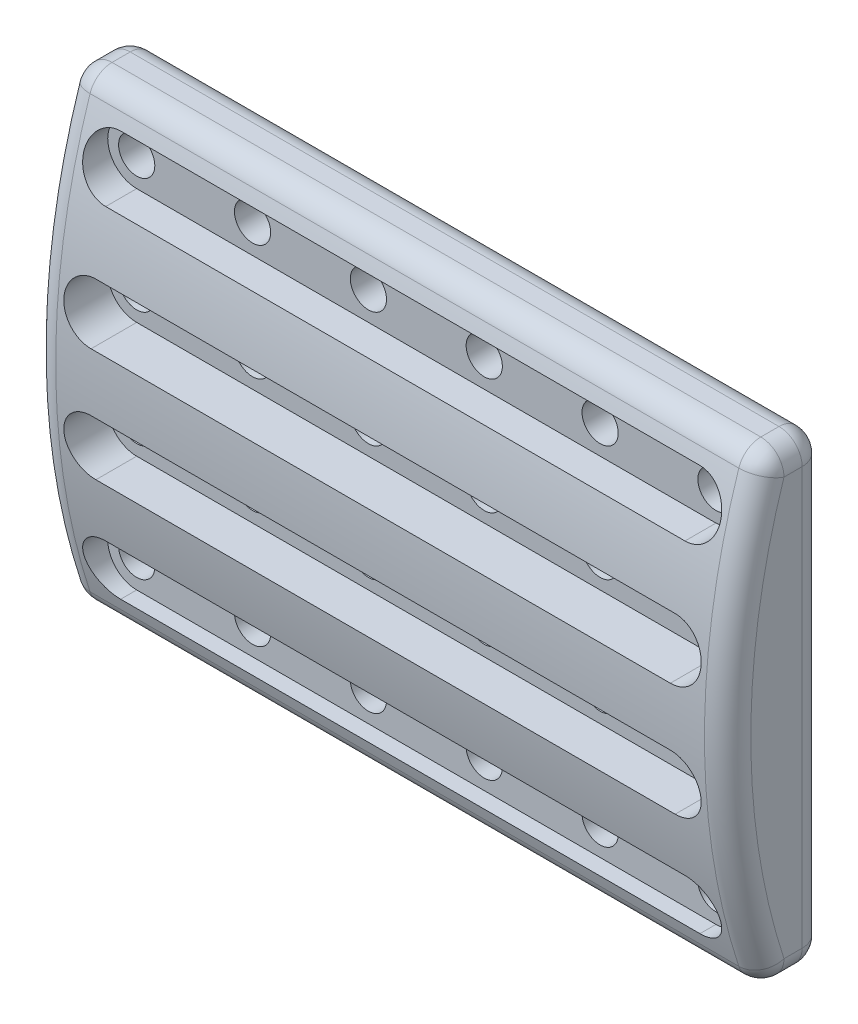
from build123d import *

# Parameters (mm, degrees)
BOSS_EXTRUDE1_DEPTH             = 76.2
FILLET1_R                       = 2.54
CUT_EXTRUDE1_DEPTH              = 5.08
F_5_32_0_15625_DIAMETER_HOLE1_D = 3.96875


with BuildPart() as part:
    # Sketch3 → Boss-Extrude1 (new body)
    with BuildSketch(Plane(origin=(0, 0, 0), x_dir=(0, 0, -1), z_dir=(1, 0, 0))):
        with BuildLine():
            ThreePointArc((-0.5955037838105575, 1.7517241379310349), (-0.3542263859949928, 1.225338953378048), (-1.2301e-13, 0.7672780265587602))
            Line((0, 0.7672780265588011), (0, 50.0327219734412))
            ThreePointArc((-1.2323e-13, 50.03272197344124), (-0.3542263859949948, 49.57466104662194), (-0.5955037838105568, 49.04827586206895))
            ThreePointArc((-0.5955037838105568, 49.04827586206895), (-4.35795103144676, 25.399999999999988), (-0.5955037838105568, 1.7517241379310349))
        make_face()
        with BuildLine():
            Line((0, 50.0327219734412), (0, 0.7672780265588011))
            ThreePointArc((-1.2301e-13, 0.7672780265587602), (0.8319424657603935, 0.19966735136426017), (1.8190813079349, -4.4e-16))
            Line((1.8190813079349, 0), (3.8099999999999925, 0))
            ThreePointArc((3.8099999999999925, 4.4e-16), (5.606051224213842, 0.7439487757861691), (6.350000000000011, 2.5400000000000182))
            Line((6.350000000000011, 2.5400000000000205), (6.3500000000000005, 48.26))
            ThreePointArc((6.350000000000003, 48.26), (5.606051224213832, 50.05605122421383), (3.81, 50.8))
            Line((3.8100000000000005, 50.8), (1.8190813079348995, 50.8))
            ThreePointArc((1.8190813079348995, 50.8), (0.8319424657603925, 50.60033264863574), (-1.2323e-13, 50.03272197344124))
        make_face()
    extrude(amount=BOSS_EXTRUDE1_DEPTH)

    # Fillet1
    fillet1_edges = [part.edges().sort_by_distance(p)[0] for p in [
        (0, 50.315945122036965, -0.3275419503675465),
        (0, 50.8, -2.81454065396745),
        (76.2, 0, -2.8145406539674465),
        (0, 50.05605122421383, -5.606051224213833),
        (0, 25.40000000000001, -6.350000000000006),
        (0, 0.7439487757861691, -5.606051224213842),
        (0, 0, -2.8145406539674465),
        (0, 0.4840548779630356, -0.32754195036755385),
        (76.2, 0.7439487757861691, -5.606051224213842),
        (76.2, 25.40000000000001, -6.350000000000006),
        (76.2, 50.05605122421383, -5.606051224213833),
        (76.2, 50.8, -2.81454065396745),
        (76.2, 50.31594512203697, -0.3275419503675483),
        (76.2, 25.399999999999988, 4.35795103144676),
        (76.2, 0.48405487796303426, -0.32754195036755385),
        (0, 25.399999999999988, 4.35795103144676),
    ]]
    fillet(fillet1_edges, radius=FILLET1_R)

    # Sketch5 → Cut-Extrude1 (cut)
    with BuildSketch(Plane(origin=(0, -9.9e-16, 4.368799999999987), x_dir=(-1, 0, 0), z_dir=(0, 2.3e-16, -1))):
        with BuildLine():
            Line((-6.3500000000000085, 47.625), (-69.85000000000002, 47.62499999999999))
            ThreePointArc((-69.85000000000002, 47.62499999999999), (-73.02500000000002, 44.449999999999996), (-69.85000000000002, 41.275))
            Line((-69.85000000000002, 41.275), (-6.3500000000000085, 41.275))
            ThreePointArc((-6.3500000000000085, 41.275), (-3.1750000000000114, 44.449999999999996), (-6.3500000000000085, 47.625))
        make_face()
        with BuildLine():
            Line((-6.34999999999987, 34.925), (-69.84999999999988, 34.925))
            ThreePointArc((-69.84999999999988, 34.925), (-73.02499999999988, 31.75), (-69.84999999999988, 28.575000000000003))
            Line((-69.84999999999988, 28.575000000000003), (-6.34999999999987, 28.575000000000003))
            ThreePointArc((-6.34999999999987, 28.575000000000003), (-3.174999999999873, 31.75), (-6.34999999999987, 34.925))
        make_face()
        with BuildLine():
            Line((-6.34999999999987, 15.875000000000014), (-69.84999999999988, 15.875000000000014))
            ThreePointArc((-69.84999999999988, 15.875000000000014), (-73.02499999999974, 19.049999999999997), (-69.84999999999988, 22.22500000000001))
            Line((-69.84999999999988, 22.22500000000001), (-6.34999999999987, 22.22500000000001))
            ThreePointArc((-6.34999999999987, 22.22500000000001), (-3.174999999999873, 19.05000000000001), (-6.34999999999987, 15.875000000000014))
        make_face()
        with BuildLine():
            Line((-6.3500000000000085, 3.1750000000000114), (-69.85000000000002, 3.175000000000018))
            ThreePointArc((-69.85000000000002, 3.175000000000018), (-73.02500000000002, 6.350000000000016), (-69.85000000000002, 9.525000000000013))
            Line((-69.85000000000002, 9.525000000000013), (-6.3500000000000085, 9.525000000000013))
            ThreePointArc((-6.3500000000000085, 9.525000000000013), (-3.1750000000000114, 6.350000000000016), (-6.3500000000000085, 3.1750000000000114))
        make_face()
    extrude(amount=CUT_EXTRUDE1_DEPTH, mode=Mode.SUBTRACT)

    # 5/32 (0.15625) Diameter Hole1 (through all)
    with Locations(Plane(origin=(6.35, 44.45, -0.7112), x_dir=(0, 1, 0), z_dir=(0, 0, 1))):
        with Locations((0, 0), (0, -12.7), (0, -25.4), (0, -38.1), (0, -50.8), (0, -63.5), (-12.7, 0), (-12.7, -12.7), (-12.7, -25.4), (-12.7, -38.1), (-12.7, -50.8), (-12.7, -63.5), (-25.4, -63.5), (-25.4, -50.8), (-25.4, -38.1), (-25.4, -25.4), (-25.4, -12.7), (-25.4, 0), (-38.1, 0), (-38.1, -12.7), (-38.1, -25.4), (-38.1, -38.1), (-38.1, -50.8), (-38.1, -63.5)):
            Hole(F_5_32_0_15625_DIAMETER_HOLE1_D / 2)


solid = part.part
